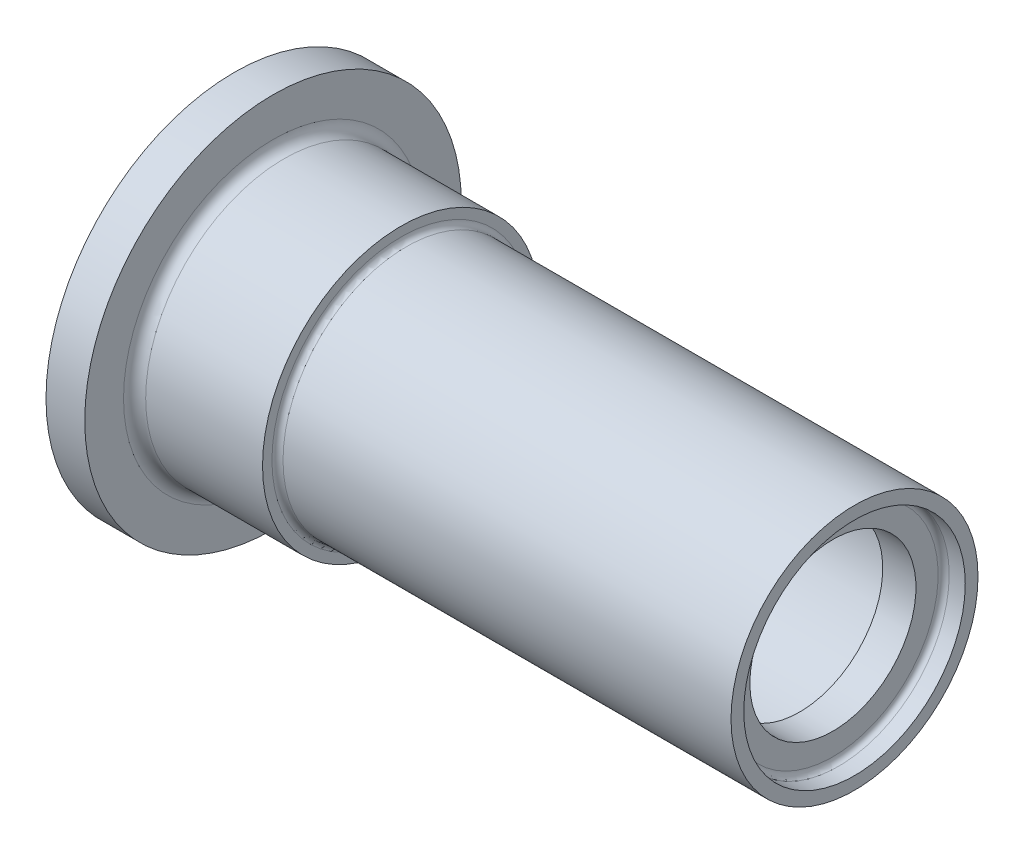
from build123d import *


with BuildPart() as part:
    # Sketch1 → Revolve1 (revolve)
    with BuildSketch(Plane.XY):
        with BuildLine():
            Line((0, 12.5), (0, 11.65))
            ThreePointArc((0, 11.65), (0.146446609, 11.296446609), (0.5, 11.15))
            Line((0.5, 11.15), (40.95, 11.15))
            Line((40.95, 11.15), (40.95, 10))
            Line((40.95, 10), (39.5, 10))
            ThreePointArc((39.5, 10), (39.146446609, 9.853553391), (39, 9.5))
            Line((39, 9.5), (39, 7.5))
            Line((39, 7.5), (36, 7.5))
            Line((36, 7.5), (36, 8.65))
            ThreePointArc((36, 8.65), (35.560660172, 9.710660172), (34.5, 10.15))
            Line((34.5, 10.15), (-13.55, 10.15))
            Line((-13.55, 10.15), (-13.55, 14.5))
            ThreePointArc((-13.55, 14.5), (-13.696446609, 14.853553391), (-14.05, 15))
            Line((-14.05, 15), (-15.05, 15))
            Line((-15.05, 15), (-15.05, 17))
            Line((-15.05, 17), (-11.55, 17))
            Line((-11.55, 17), (-11.55, 13.5))
            ThreePointArc((-11.55, 13.5), (-11.257106781, 12.792893219), (-10.55, 12.5))
            Line((-10.55, 12.5), (0, 12.5))
        make_face()
    revolve(axis=Axis((-88.99, 0, 0), (1, 0, 0)))


solid = part.part
